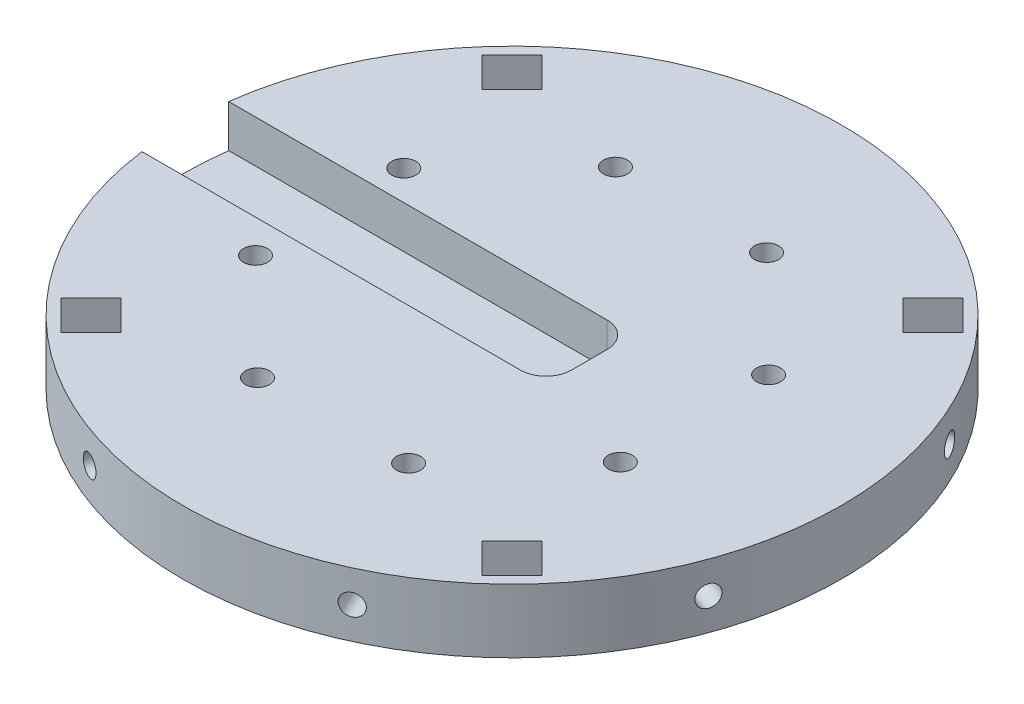
from build123d import *

# Parameters (mm, degrees)
SKETCH1_R           = 98.425
BOSS_EXTRUDE1_DEPTH = 19.05
SKETCH3_R           = 3.5941
CUT_EXTRUDE4_DEPTH  = 19.05
CIRPATTERN2_COUNT   = 8
CUT_EXTRUDE5_DEPTH  = 12.7
CUT_EXTRUDE7_DEPTH  = 19.05
CIRPATTERN4_COUNT   = 4
SKETCH5_R           = 3.175
CUT_EXTRUDE8_DEPTH  = 12.7
CIRPATTERN5_COUNT   = 8
FILLET1_R           = 7.62


with BuildPart() as part:
    # Sketch1 → Boss-Extrude1 (new body)
    with BuildSketch(Plane(origin=(0, 0, 0), x_dir=(1, 0, 0), z_dir=(0, 1, 0))):
        Circle(SKETCH1_R)
    extrude(amount=BOSS_EXTRUDE1_DEPTH)

    # Sketch3 → Cut-Extrude4 (cut)
    with BuildSketch(Plane(origin=(0, 19.05, 0), x_dir=(1, 0, 0), z_dir=(0, 1, 0))):
        with Locations((-22.866976578, 53.758699595)):
            Circle(SKETCH3_R)
    cut_extrude4 = extrude(amount=-CUT_EXTRUDE4_DEPTH, mode=Mode.SUBTRACT)

    # CirPattern2: Cut-Extrude4 ×8 about axis
    cirpattern2_axis = Axis((0, 0, 0), (0, 1, 0))
    for i in range(1, CIRPATTERN2_COUNT):
        add(cut_extrude4.rotate(cirpattern2_axis, i * 360 / CIRPATTERN2_COUNT), mode=Mode.SUBTRACT)

    # Sketch4 → Cut-Extrude5 (cut)
    with BuildSketch(Plane(origin=(0, 19.05, 0), x_dir=(1, 0, 0), z_dir=(0, 1, 0))):
        with BuildLine():
            Line((-97.568819348, 12.954), (23.081180652, 12.954))
            Line((23.081180652, 12.954), (23.081180652, -12.954))
            Line((23.081180652, -12.954), (-97.568819348, -12.954))
            ThreePointArc((-97.568819348, -12.954), (-98.425, 0), (-97.568819348, 12.954))
        make_face()
    extrude(amount=-CUT_EXTRUDE5_DEPTH, mode=Mode.SUBTRACT)

    # Sketch2 → Cut-Extrude7 (cut)
    with BuildSketch(Plane(origin=(0, 19.05, 0), x_dir=(1, 0, 0), z_dir=(0, 1, 0))):
        Polygon((53.881536726, 62.861792847), (62.861792847, 71.842048969), (71.842048969, 62.861792847), (62.861792847, 53.881536726), align=None)
    cut_extrude7 = extrude(amount=-CUT_EXTRUDE7_DEPTH, mode=Mode.SUBTRACT)

    # CirPattern4: Cut-Extrude7 ×4 about axis
    cirpattern4_axis = Axis((0, 0, 0), (0, 1, 0))
    for i in range(1, CIRPATTERN4_COUNT):
        add(cut_extrude7.rotate(cirpattern4_axis, i * 360 / CIRPATTERN4_COUNT), mode=Mode.SUBTRACT)

    # Sketch5 → Cut-Extrude8 (cut)
    with BuildSketch(Plane(origin=(-33.663332607, 0, 92.489246201), x_dir=(0, -1, 0), z_dir=(-0.342020143, 0, 0.939692621))):
        with Locations((-9.525, -0.112232827)):
            Circle(SKETCH5_R)
    cut_extrude8 = extrude(amount=-CUT_EXTRUDE8_DEPTH, mode=Mode.SUBTRACT)

    # CirPattern5: Cut-Extrude8 ×8 about axis
    cirpattern5_axis = Axis((0, 0, 0), (0, 1, 0))
    for i in range(1, CIRPATTERN5_COUNT):
        add(cut_extrude8.rotate(cirpattern5_axis, i * 360 / CIRPATTERN5_COUNT), mode=Mode.SUBTRACT)

    # Fillet1
    fillet1_edges = [part.edges().sort_by_distance(p)[0] for p in [
        (23.081180652, 12.7, -12.954),
        (23.081180652, 12.7, 12.954),
    ]]
    fillet(fillet1_edges, radius=FILLET1_R)


solid = part.part
